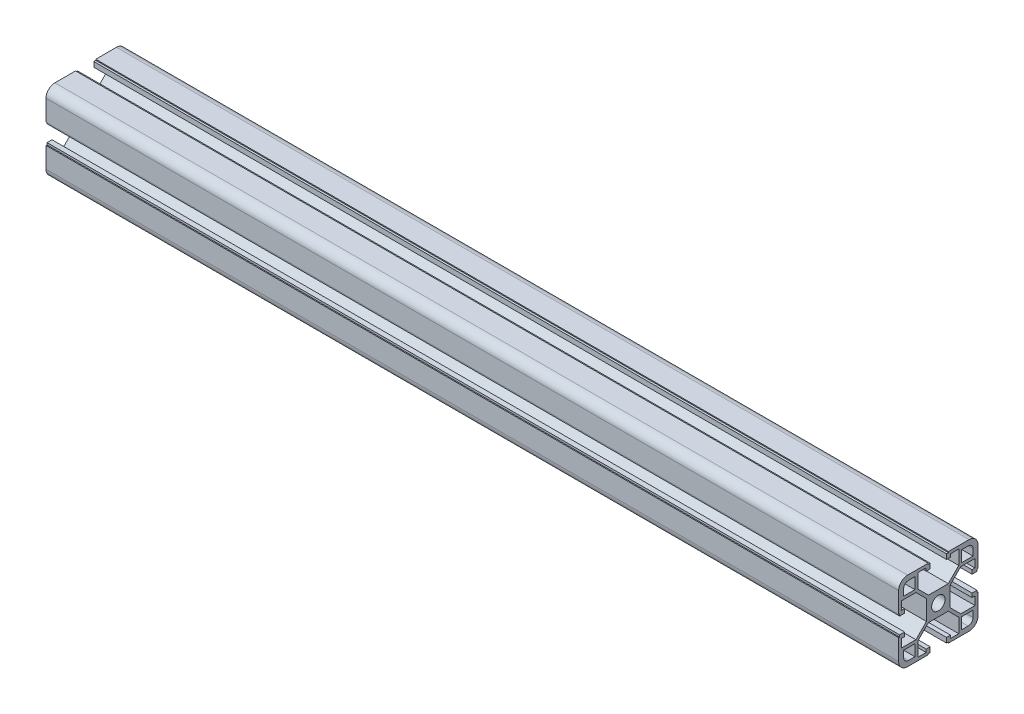
from build123d import *

# Parameters (mm, degrees)
SKETCH1_R                 = 3.4
F_40_X_40L_X_R4_5_1_DEPTH = 430
SKETCH_2_R                = 2.5
CUT_EXTRUDE_1_DEPTH       = 220.60191256


with BuildPart() as part:
    # Sketch1 → 铝型材 40 X 40L X R4.5(1) (new body)
    with BuildSketch(Plane(origin=(-215, 0, 0), x_dir=(0, 0, -1), z_dir=(1, 0, 0))):
        with BuildLine():
            Line((-5.1, 20), (-5.1, 19.5))
            Line((-5.1, 19.5), (-4.1, 19.5))
            Line((-4.1, 19.5), (-4.1, 17))
            Line((-4.1, 17), (-6.1, 17))
            Line((-6.1, 17), (-6.1, 18.5))
            Line((-6.1, 18.5), (-10.3, 18.5))
            Line((-10.3, 18.5), (-10.3, 11.3))
            Line((-10.3, 11.3), (-5, 6))
            Line((-5, 6), (5, 6))
            Line((5, 6), (10.3, 11.3))
            Line((10.3, 11.3), (10.3, 18.5))
            Line((10.3, 18.5), (6.1, 18.5))
            Line((6.1, 18.5), (6.1, 17))
            Line((6.1, 17), (4.1, 17))
            Line((4.1, 17), (4.1, 19.5))
            Line((4.1, 19.5), (5.1, 19.5))
            Line((5.1, 19.5), (5.1, 20))
            Line((5.1, 20), (15.5, 20))
            ThreePointArc((15.5, 20), (18.681980515, 18.681980515), (20, 15.5))
            Line((20, 15.5), (20, 5.1))
            Line((20, 5.1), (19.5, 5.1))
            Line((19.5, 5.1), (19.5, 4.1))
            Line((19.5, 4.1), (17, 4.1))
            Line((17, 4.1), (17, 6.1))
            Line((17, 6.1), (18.5, 6.1))
            Line((18.5, 6.1), (18.5, 10.3))
            Line((18.5, 10.3), (11.3, 10.3))
            Line((11.3, 10.3), (6, 5))
            Line((6, 5), (6, -5))
            Line((6, -5), (11.3, -10.3))
            Line((11.3, -10.3), (18.5, -10.3))
            Line((18.5, -10.3), (18.5, -6.1))
            Line((18.5, -6.1), (17, -6.1))
            Line((17, -6.1), (17, -4.1))
            Line((17, -4.1), (19.5, -4.1))
            Line((19.5, -4.1), (19.5, -5.1))
            Line((19.5, -5.1), (20, -5.1))
            Line((20, -5.1), (20, -15.5))
            ThreePointArc((20, -15.5), (18.681980515, -18.681980515), (15.5, -20))
            Line((15.5, -20), (5.1, -20))
            Line((5.1, -20), (5.1, -19.5))
            Line((5.1, -19.5), (4.1, -19.5))
            Line((4.1, -19.5), (4.1, -17))
            Line((4.1, -17), (6.1, -17))
            Line((6.1, -17), (6.1, -18.5))
            Line((6.1, -18.5), (10.3, -18.5))
            Line((10.3, -18.5), (10.3, -11.3))
            Line((10.3, -11.3), (5, -6))
            Line((5, -6), (-5, -6))
            Line((-5, -6), (-10.3, -11.3))
            Line((-10.3, -11.3), (-10.3, -18.5))
            Line((-10.3, -18.5), (-6.1, -18.5))
            Line((-6.1, -18.5), (-6.1, -17))
            Line((-6.1, -17), (-4.1, -17))
            Line((-4.1, -17), (-4.1, -19.5))
            Line((-4.1, -19.5), (-5.1, -19.5))
            Line((-5.1, -19.5), (-5.1, -20))
            Line((-5.1, -20), (-15.5, -20))
            ThreePointArc((-15.5, -20), (-18.681980515, -18.681980515), (-20, -15.5))
            Line((-20, -15.5), (-20, -5.1))
            Line((-20, -5.1), (-19.5, -5.1))
            Line((-19.5, -5.1), (-19.5, -4.1))
            Line((-19.5, -4.1), (-17, -4.1))
            Line((-17, -4.1), (-17, -6.1))
            Line((-17, -6.1), (-18.5, -6.1))
            Line((-18.5, -6.1), (-18.5, -10.3))
            Line((-18.5, -10.3), (-11.3, -10.3))
            Line((-11.3, -10.3), (-6, -5))
            Line((-6, -5), (-6, 5))
            Line((-6, 5), (-11.3, 10.3))
            Line((-11.3, 10.3), (-18.5, 10.3))
            Line((-18.5, 10.3), (-18.5, 6.1))
            Line((-18.5, 6.1), (-17, 6.1))
            Line((-17, 6.1), (-17, 4.1))
            Line((-17, 4.1), (-19.5, 4.1))
            Line((-19.5, 4.1), (-19.5, 5.1))
            Line((-19.5, 5.1), (-20, 5.1))
            Line((-20, 5.1), (-20, 15.5))
            ThreePointArc((-20, 15.5), (-18.681980515, 18.681980515), (-15.5, 20))
            Line((-15.5, 20), (-5.1, 20))
        make_face()
        Circle(SKETCH1_R, mode=Mode.SUBTRACT)
        with BuildLine():
            Line((11.8, 17.5), (15, 17.5))
            ThreePointArc((15, 17.5), (16.767766953, 16.767766953), (17.5, 15))
            Line((17.5, 15), (17.5, 11.8))
            Line((17.5, 11.8), (11.8, 11.8))
            Line((11.8, 11.8), (11.8, 17.5))
        make_face(mode=Mode.SUBTRACT)
        with BuildLine():
            Line((-15, 17.5), (-11.8, 17.5))
            Line((-11.8, 17.5), (-11.8, 11.8))
            Line((-11.8, 11.8), (-17.5, 11.8))
            Line((-17.5, 11.8), (-17.5, 15))
            ThreePointArc((-17.5, 15), (-16.767766953, 16.767766953), (-15, 17.5))
        make_face(mode=Mode.SUBTRACT)
        with BuildLine():
            Line((-17.5, -11.8), (-11.8, -11.8))
            Line((-11.8, -11.8), (-11.8, -17.5))
            Line((-11.8, -17.5), (-15, -17.5))
            ThreePointArc((-15, -17.5), (-16.767766953, -16.767766953), (-17.5, -15))
            Line((-17.5, -15), (-17.5, -11.8))
        make_face(mode=Mode.SUBTRACT)
        with BuildLine():
            Line((11.8, -11.8), (17.5, -11.8))
            Line((17.5, -11.8), (17.5, -15))
            ThreePointArc((17.5, -15), (16.767766953, -16.767766953), (15, -17.5))
            Line((15, -17.5), (11.8, -17.5))
            Line((11.8, -17.5), (11.8, -11.8))
        make_face(mode=Mode.SUBTRACT)
    extrude(amount=F_40_X_40L_X_R4_5_1_DEPTH)

    # 草图2 → 切除-拉伸1 (cut, through all)
    with BuildSketch(Plane(origin=(0, 20, 0), x_dir=(1, 0, 0), z_dir=(0, 1, 0))):
        with Locations(Location((-1, 0, 0), (0, 0, 270))):
            Circle(SKETCH_2_R)
        with Locations(Location((108, 0, 0), (0, 0, 270))):
            Circle(SKETCH_2_R)
    extrude(amount=-CUT_EXTRUDE_1_DEPTH, mode=Mode.SUBTRACT)


solid = part.part
